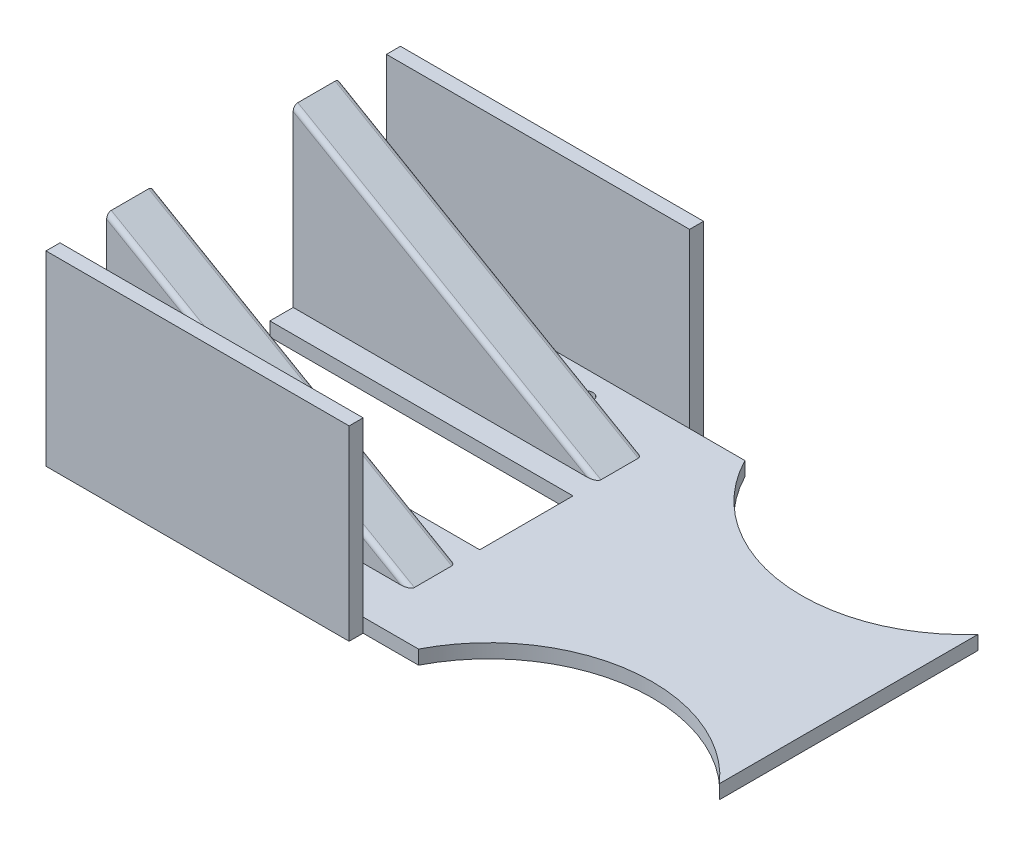
from build123d import *

# Parameters (mm, degrees)
SKETCH_1_W           = 220
SKETCH_1_H           = 70
EXTRUDE_1_DEPTH      = 3
EXTRUDE_2_DEPTH      = 25
EXTRUDE_2_DEPTH_BACK = 25
SKETCH_6_W           = 30
SKETCH_6_H           = 37.527767497
CUT_EXTRUDE_4_DEPTH  = 221
SKETCH_7_R           = 35
CUT_EXTRUDE_5_DEPTH  = 4
SKETCH_8_W           = 3
SKETCH_8_H           = 40
EXTRUDE_3_DEPTH      = 65
SKETCH_9_R           = 1.5
CUT_EXTRUDE_6_DEPTH  = 4
FILLET_5_R           = 1
SKETCH_10_W          = 65
SKETCH_10_H          = 20
CUT_EXTRUDE_7_DEPTH  = 4
SKETCH_12_R          = 1.5
CUT_EXTRUDE_8_DEPTH  = 4


with BuildPart() as part:
    # 草图1 → 凸台-拉伸1 (new body)
    with BuildSketch(Plane(origin=(0, 0, 0), x_dir=(1, 0, 0), z_dir=(0, 1, 0))):
        with Locations((27.295373665, 0)):
            Rectangle(SKETCH_1_W, SKETCH_1_H)
    extrude(amount=EXTRUDE_1_DEPTH)

    # 草图2 → 凸台-拉伸2 (add, two sides)
    with BuildSketch(Plane.XY) as extrude_2_sk:
        Polygon((-82.704626335, 40.527767497), (-82.704626335, 3), (-17.704626335, 3), align=None)
    extrude(amount=EXTRUDE_2_DEPTH)
    extrude(extrude_2_sk.sketch, amount=-EXTRUDE_2_DEPTH_BACK)

    # 草图6 → 切除-拉伸4 (cut, through all)
    with BuildSketch(Plane.ZY.offset(82.704626335)):
        with Locations((0, 21.763883748)):
            Rectangle(SKETCH_6_W, SKETCH_6_H)
    extrude(amount=-CUT_EXTRUDE_4_DEPTH, mode=Mode.SUBTRACT)

    # 草图7 → 切除-拉伸5 (cut, through all)
    with BuildSketch(Plane(origin=(0, 3, 0), x_dir=(1, 0, 0), z_dir=(0, 1, 0))):
        with Locations((25.295373665, 51)):
            Circle(SKETCH_7_R)
        with Locations((25.295373665, -51)):
            Circle(SKETCH_7_R)
    extrude(amount=-CUT_EXTRUDE_5_DEPTH, mode=Mode.SUBTRACT)

    # 草图8 → 凸台-拉伸3 (add)
    with BuildSketch(Plane.ZY.offset(82.704626335)):
        with Locations((36.5, 20)):
            Rectangle(SKETCH_8_W, SKETCH_8_H)
        with Locations((-36.5, 20)):
            Rectangle(SKETCH_8_W, SKETCH_8_H)
    extrude(amount=-EXTRUDE_3_DEPTH)

    # 草图9 → 切除-拉伸6 (cut, through all)
    with BuildSketch(Plane(origin=(0, 3, 0), x_dir=(1, 0, 0), z_dir=(0, 1, 0))):
        with Locations((-74.766784803, 29.860059225)):
            Circle(SKETCH_9_R)
        with Locations((-54.766784803, 29.860059225)):
            Circle(SKETCH_9_R)
        with Locations((-34.766784803, 29.860059225)):
            Circle(SKETCH_9_R)
        with Locations((-34.766784803, -29.860059225)):
            Circle(SKETCH_9_R)
        with Locations((-54.766784803, -29.860059225)):
            Circle(SKETCH_9_R)
        with Locations((-74.766784803, -29.860059225)):
            Circle(SKETCH_9_R)
        with Locations((68.031562246, 22)):
            Circle(SKETCH_9_R)
        with Locations((88.031562246, 22)):
            Circle(SKETCH_9_R)
        with Locations((108.031562246, 22)):
            Circle(SKETCH_9_R)
        with Locations((108.031562246, -22)):
            Circle(SKETCH_9_R)
        with Locations((88.031562246, -22)):
            Circle(SKETCH_9_R)
        with Locations((68.031562246, -22)):
            Circle(SKETCH_9_R)
        with Locations((128.031562246, 22)):
            Circle(SKETCH_9_R)
        with Locations((128.031562246, -22)):
            Circle(SKETCH_9_R)
    extrude(amount=-CUT_EXTRUDE_6_DEPTH, mode=Mode.SUBTRACT)

    # 圆角5
    fillet_5_edges = [part.edges().sort_by_distance(p)[0] for p in [
        (-50.204626335, 21.763883749, -25),
        (-50.204626335, 21.763883749, 25),
        (-50.204626335, 21.763883749, -15),
        (-50.204626335, 21.763883749, 15),
    ]]
    fillet(fillet_5_edges, radius=FILLET_5_R)

    # 草图10 → 切除-拉伸7 (cut, through all)
    with BuildSketch(Plane(origin=(0, 3, 0), x_dir=(1, 0, 0), z_dir=(0, 1, 0))):
        with Locations((-50.204626335, 0)):
            Rectangle(SKETCH_10_W, SKETCH_10_H)
    extrude(amount=-CUT_EXTRUDE_7_DEPTH, mode=Mode.SUBTRACT)

    # 草图12 → 切除-拉伸8 (cut, through all)
    with BuildSketch(Plane(origin=(0, 3, 0), x_dir=(1, 0, 0), z_dir=(0, 1, 0))):
        with BuildLine():
            Line((51.424138498, 27.712929589), (51.424138498, 0))
            Line((51.424138498, 0), (51.424138498, -27.712929589))
            ThreePointArc((51.424138498, -27.712929589), (54.155060508, -31.198018398), (56.424138498, -35))
            Line((56.424138498, -35), (137.295373665, -35))
            Line((137.295373665, -35), (137.295373665, 35))
            Line((137.295373665, 35), (56.424138498, 35))
            ThreePointArc((56.424138498, 35), (54.155060508, 31.198018398), (51.424138498, 27.712929589))
        make_face()
        with Locations((68.031562246, -22)):
            Circle(SKETCH_12_R, mode=Mode.SUBTRACT)
        with Locations((88.031562246, -22)):
            Circle(SKETCH_12_R, mode=Mode.SUBTRACT)
        with Locations((108.031562246, -22)):
            Circle(SKETCH_12_R, mode=Mode.SUBTRACT)
        with Locations((128.031562246, -22)):
            Circle(SKETCH_12_R, mode=Mode.SUBTRACT)
        with Locations((68.031562246, 22)):
            Circle(SKETCH_12_R, mode=Mode.SUBTRACT)
        with Locations((88.031562246, 22)):
            Circle(SKETCH_12_R, mode=Mode.SUBTRACT)
        with Locations((108.031562246, 22)):
            Circle(SKETCH_12_R, mode=Mode.SUBTRACT)
        with Locations((128.031562246, 22)):
            Circle(SKETCH_12_R, mode=Mode.SUBTRACT)
    extrude(amount=-CUT_EXTRUDE_8_DEPTH, mode=Mode.SUBTRACT)


solid = part.part
